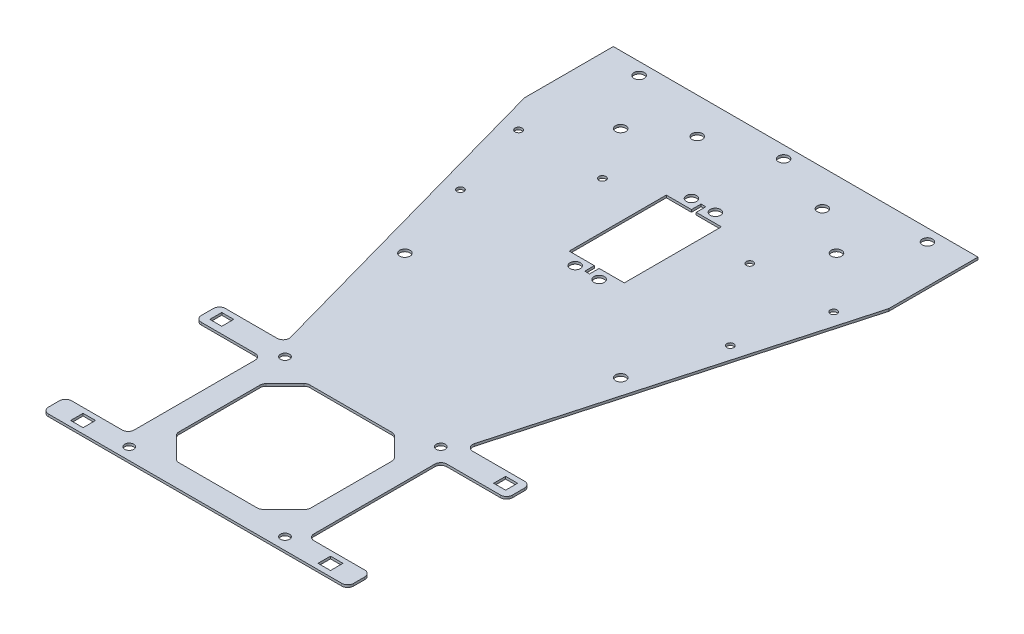
from build123d import *

# Parameters (mm, degrees)
SKETCH26_R          = 1.875
SKETCH26_W          = 5
SKETCH26_H          = 5
SKETCH26_R_2        = 2.15
SKETCH26_R_3        = 1.45
BOSS_EXTRUDE6_DEPTH = 1


with BuildPart() as part:
    # Sketch26 → Boss-Extrude6 (new body)
    with BuildSketch(Plane(origin=(0, 0, 0), x_dir=(1, 0, 0), z_dir=(0, 1, 0))):
        with BuildLine():
            Line((76.013272408, 51.623832483), (76.013272408, 88.823544949))
            Line((76.013272408, 88.823544949), (-76.102081629, 88.823544949))
            Line((-76.102081629, 88.823544949), (-76.102081629, 51.776273242))
            Line((-76.102081629, 51.776273242), (-38.382791234, -83.527277546))
            ThreePointArc((-38.382791234, -83.527277546), (-38.800395788, -85.710062519), (-40.791178841, -86.69785128))
            Line((-40.791178841, -86.69785128), (-62.37853755, -86.69785128))
            ThreePointArc((-62.37853755, -86.69785128), (-64.146304503, -87.430084327), (-64.87853755, -89.19785128))
            Line((-64.87853755, -89.19785128), (-64.87853755, -94.216442532))
            ThreePointArc((-64.87853755, -94.216442532), (-64.146304503, -95.984209485), (-62.37853755, -96.716442532))
            Line((-62.37853755, -96.716442532), (-40, -96.716442532))
            ThreePointArc((-40, -96.716442532), (-38.232233047, -97.448675579), (-37.5, -99.216442532))
            Line((-37.5, -99.216442532), (-37.5, -149.615103737))
            ThreePointArc((-37.5, -149.615103737), (-38.232233047, -151.38287069), (-40, -152.115103737))
            Line((-40, -152.115103737), (-61.156929158, -152.115103737))
            ThreePointArc((-61.156929158, -152.115103737), (-62.924696111, -152.847336784), (-63.656929158, -154.615103737))
            Line((-63.656929158, -154.615103737), (-63.656929158, -159.216442532))
            ThreePointArc((-63.656929158, -159.216442532), (-62.924696111, -160.984209485), (-61.156929158, -161.716442532))
            Line((-61.156929158, -161.716442532), (-34.988305588, -161.716442532))
            Line((-34.988305588, -161.716442532), (-29.988305588, -161.716442532))
            Line((-29.988305588, -161.716442532), (30, -161.716442532))
            Line((30, -161.716442532), (61.156929158, -161.716442532))
            ThreePointArc((61.156929158, -161.716442532), (62.924696111, -160.984209485), (63.656929158, -159.216442532))
            Line((63.656929158, -159.216442532), (63.656929158, -154.615103737))
            ThreePointArc((63.656929158, -154.615103737), (62.924696111, -152.847336784), (61.156929158, -152.115103737))
            Line((61.156929158, -152.115103737), (40, -152.115103737))
            ThreePointArc((40, -152.115103737), (38.232233047, -151.38287069), (37.5, -149.615103737))
            Line((37.5, -149.615103737), (37.5, -99.216442532))
            ThreePointArc((37.5, -99.216442532), (38.232233047, -97.448675579), (40, -96.716442532))
            Line((40, -96.716442532), (62.37853755, -96.716442532))
            ThreePointArc((62.37853755, -96.716442532), (64.146304503, -95.984209485), (64.87853755, -94.216442532))
            Line((64.87853755, -94.216442532), (64.87853755, -89.19785128))
            ThreePointArc((64.87853755, -89.19785128), (64.146304503, -87.430084327), (62.37853755, -86.69785128))
            Line((62.37853755, -86.69785128), (40.791178841, -86.69785128))
            ThreePointArc((40.791178841, -86.69785128), (38.800395788, -85.710062519), (38.382791234, -83.527277546))
            Line((38.382791234, -83.527277546), (75.505468817, 49.800039197))
            Line((75.505468817, 49.800039197), (76.013272408, 51.623832483))
        make_face()
        Polygon((-54.2, -154.243772746), (-49, -154.243772746), (-49, -159.443772746), (-54.2, -159.443772746), (-54.2, -156.286487859), align=None, mode=Mode.SUBTRACT)
        with Locations((-32.5, -156.716442532)):
            Circle(SKETCH26_R, mode=Mode.SUBTRACT)
        with Locations((-59.2, -91.39597875)):
            Rectangle(SKETCH26_W, SKETCH26_H, mode=Mode.SUBTRACT)
        with Locations((-32.5, -91.716442532)):
            Circle(SKETCH26_R, mode=Mode.SUBTRACT)
        with Locations((32.5, -156.716442532)):
            Circle(SKETCH26_R, mode=Mode.SUBTRACT)
        with BuildLine():
            Line((27.5, -107.101933172), (27.5, -140.94514821))
            ThreePointArc((27.5, -140.94514821), (27.309376305, -141.902635067), (26.766575135, -142.714106178))
            Line((26.766575135, -142.714106178), (18.084925196, -151.384061705))
            ThreePointArc((18.084925196, -151.384061705), (17.274280257, -151.925124832), (16.318350061, -152.115103737))
            Line((16.318350061, -152.115103737), (-16.318350061, -152.115103737))
            ThreePointArc((-16.318350061, -152.115103737), (-17.275058642, -151.924802568), (-18.086117014, -151.38287069))
            Line((-18.086117014, -151.38287069), (-26.764204101, -142.704783602))
            ThreePointArc((-26.764204101, -142.704783602), (-27.306229203, -141.89350014), (-27.496437101, -140.936529386))
            Line((-27.496437101, -140.936529386), (-27.489840484, -107.09128644))
            ThreePointArc((-27.489840484, -107.09128644), (-27.299446118, -106.134840041), (-26.757607485, -105.324006751))
            Line((-26.757607485, -105.324006751), (-18.882276313, -97.448675579))
            ThreePointArc((-18.882276313, -97.448675579), (-18.071217941, -96.906743701), (-17.11450936, -96.716442532))
            Line((-17.11450936, -96.716442532), (17.11450936, -96.716442532))
            ThreePointArc((17.11450936, -96.716442532), (18.071217941, -96.906743701), (18.882276313, -97.448675579))
            Line((18.882276313, -97.448675579), (26.767766953, -105.334166219))
            ThreePointArc((26.767766953, -105.334166219), (27.309698831, -106.145224591), (27.5, -107.101933172))
        make_face(mode=Mode.SUBTRACT)
        Polygon((54.2, -159.443772746), (49, -159.443772746), (49, -154.243772746), (54.2, -154.243772746), (54.2, -156.286487859), align=None, mode=Mode.SUBTRACT)
        with Locations((32.5, -91.716442532)):
            Circle(SKETCH26_R, mode=Mode.SUBTRACT)
        with Locations((59.2, -91.39597875)):
            Rectangle(SKETCH26_W, SKETCH26_H, mode=Mode.SUBTRACT)
        with Locations((-44.91002895, -29.282587791)):
            Circle(SKETCH26_R_2, mode=Mode.SUBTRACT)
        with Locations((-56.275133419, 5.22710987)):
            Circle(SKETCH26_R_3, mode=Mode.SUBTRACT)
        with Locations((-4.91002895, 1.717412209)):
            Circle(SKETCH26_R_2, mode=Mode.SUBTRACT)
        with Locations((-65.710275059, 38.931384113)):
            Circle(SKETCH26_R_3, mode=Mode.SUBTRACT)
        with Locations((-60.263272408, 83.747616616)):
            Circle(SKETCH26_R_2, mode=Mode.SUBTRACT)
        with Locations((-44.91002895, 60.717412209)):
            Circle(SKETCH26_R_2, mode=Mode.SUBTRACT)
        with Locations((-30.728022224, 38.916998548)):
            Circle(SKETCH26_R_3, mode=Mode.SUBTRACT)
        with Locations((-4.91002895, 50.217412209)):
            Circle(SKETCH26_R_2, mode=Mode.SUBTRACT)
        with Locations((-26.102081629, 73.823544949)):
            Circle(SKETCH26_R_2, mode=Mode.SUBTRACT)
        with Locations((5.08997105, 1.717412209)):
            Circle(SKETCH26_R_2, mode=Mode.SUBTRACT)
        Polygon((11.577692982, 46.217412209), (11.577692982, 5.717412209), (1.08997105, 5.717412209), (1.08997105, 1.717412209), (-0.91002895, 1.717412209), (-0.91002895, 5.717412209), (-11.397750883, 5.717412209), (-11.397750883, 46.217412209), (-0.91002895, 46.217412209), (-0.91002895, 50.217412209), (1.08997105, 50.217412209), (1.08997105, 46.217412209), align=None, mode=Mode.SUBTRACT)
        with Locations((45.08997105, -29.282587791)):
            Circle(SKETCH26_R_2, mode=Mode.SUBTRACT)
        with Locations((56.339989947, 5.199572045)):
            Circle(SKETCH26_R_3, mode=Mode.SUBTRACT)
        with Locations((5.08997105, 50.217412209)):
            Circle(SKETCH26_R_2, mode=Mode.SUBTRACT)
        with Locations((30.728022224, 38.916998548)):
            Circle(SKETCH26_R_3, mode=Mode.SUBTRACT)
        with Locations((0, 83.74802142)):
            Circle(SKETCH26_R_2, mode=Mode.SUBTRACT)
        with Locations((26.102081629, 73.823544949)):
            Circle(SKETCH26_R_2, mode=Mode.SUBTRACT)
        with Locations((65.728022224, 38.916998548)):
            Circle(SKETCH26_R_3, mode=Mode.SUBTRACT)
        with Locations((45.08997105, 60.717412209)):
            Circle(SKETCH26_R_2, mode=Mode.SUBTRACT)
        with Locations((59.999999999, 83.747618385)):
            Circle(SKETCH26_R_2, mode=Mode.SUBTRACT)
    extrude(amount=BOSS_EXTRUDE6_DEPTH)


solid = part.part
